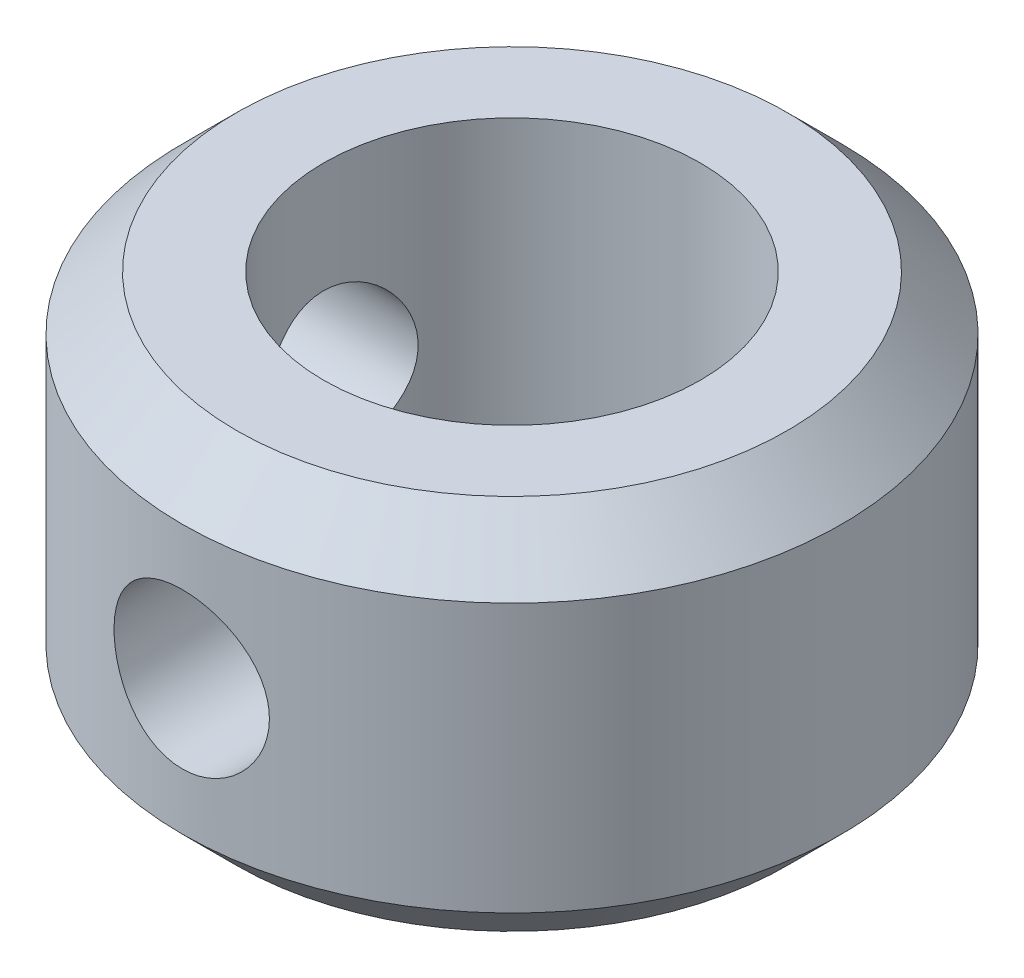
from build123d import *

# Parameters (mm, degrees)
SKETCH1_R                  = 7
SKETCH1_R_2                = 4
BOSS_EXTRUDE1_DEPTH        = 4
M4X0_7_TAPPED_HOLE1_REACH  = 18.155
M4X0_7_TAPPED_HOLE1_BORE_R = 1.65
CHAMFER1_SIZE              = 1.15
CIRPATTERN1_COUNT          = 2
CIRPATTERN1_ANGLE          = 90


with BuildPart() as part:
    # Sketch1 → Boss-Extrude1 (new, symmetric)
    with BuildSketch(Plane(origin=(0, 0, 0), x_dir=(1, 0, 0), z_dir=(0, 1, 0))):
        with Locations(Location((0, 0, 0), (0, 0, 270))):
            Circle(SKETCH1_R)
        with Locations(Location((0, 0, 0), (0, 0, 270))):
            Circle(SKETCH1_R_2, mode=Mode.SUBTRACT)
    extrude(amount=BOSS_EXTRUDE1_DEPTH, both=True)

    # M4x0.7 Tapped Hole1 bore → M4x0.7 Tapped Hole1 (cut, up to next)
    with BuildSketch(Plane.XY.offset(7), mode=Mode.PRIVATE) as m4x0_7_tapped_hole1_sk1:
        Circle(M4X0_7_TAPPED_HOLE1_BORE_R)
    m4x0_7_tapped_hole1_tool1 = extrude(m4x0_7_tapped_hole1_sk1.sketch, amount=-M4X0_7_TAPPED_HOLE1_REACH, mode=Mode.PRIVATE) & part.part
    m4x0_7_tapped_hole1 = m4x0_7_tapped_hole1_tool1.solids().sort_by_distance((0, 0, 7))[0]
    add(m4x0_7_tapped_hole1, mode=Mode.SUBTRACT)

    # Chamfer1
    chamfer1_edges = [part.edges().sort_by_distance(p)[0] for p in [
        (0, -4, -7),
        (0, 4, -7),
    ]]
    chamfer(chamfer1_edges, length=CHAMFER1_SIZE)

    # CirPattern1: M4x0.7 Tapped Hole1 ×2 about axis
    cirpattern1_axis = Axis((0, 4, 0), (0, -1, 0))
    for i in range(1, CIRPATTERN1_COUNT):
        add(m4x0_7_tapped_hole1.rotate(cirpattern1_axis, i * CIRPATTERN1_ANGLE / (CIRPATTERN1_COUNT - 1)), mode=Mode.SUBTRACT)


solid = part.part
